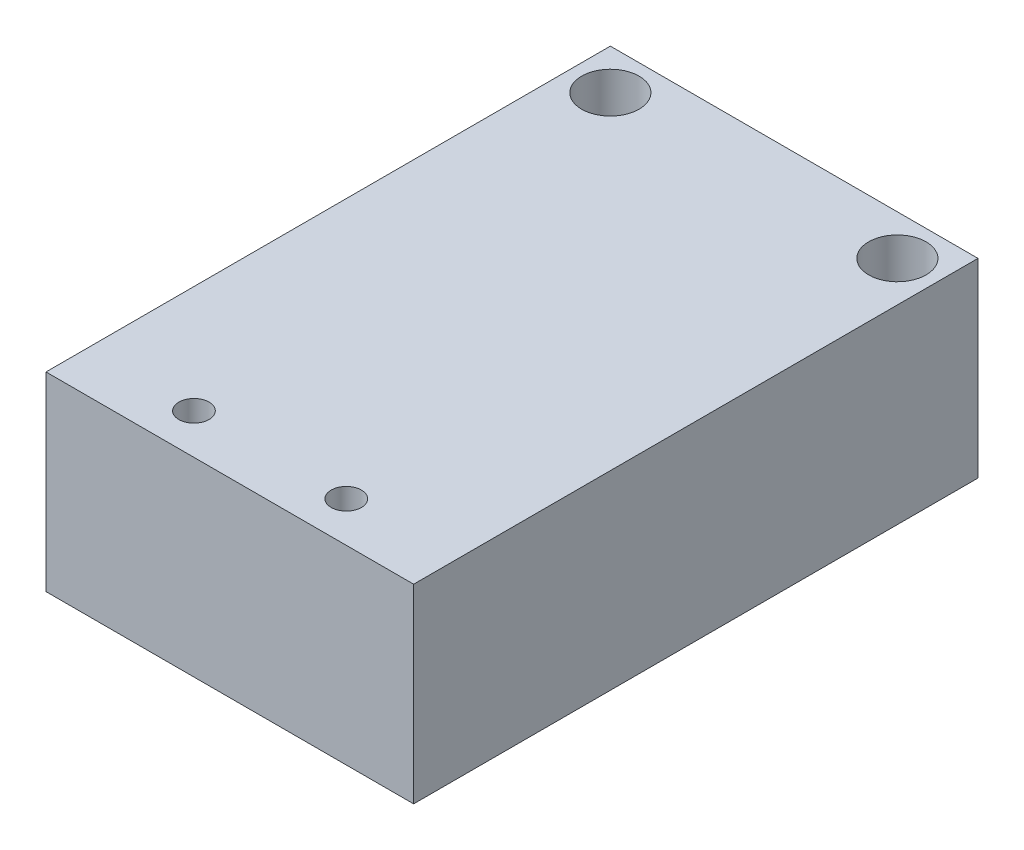
from build123d import *

# Parameters (mm, degrees)
SKETCH1_W             = 14.478
SKETCH1_H             = 22.225
BOSS_EXTRUDE1_DEPTH   = 7.493
F_0_80_TAPPED_HOLE1_D = 1.19126
F_2_CLEARANCE_HOLE1_D = 2.2606


with BuildPart() as part:
    # Sketch1 → Boss-Extrude1 (new body)
    with BuildSketch(Plane(origin=(0, 0, 0), x_dir=(1, 0, 0), z_dir=(0, 1, 0))):
        Rectangle(SKETCH1_W, SKETCH1_H)
    extrude(amount=BOSS_EXTRUDE1_DEPTH)

    # #0-80 Tapped Hole1 (through all)
    with Locations(Plane(origin=(0, 7.493, 0), x_dir=(-1, 0, 0), z_dir=(0, 1, 0))):
        with Locations((3, 9.525), (-3, 9.525)):
            Hole(F_0_80_TAPPED_HOLE1_D / 2)

    # #2 Clearance Hole1 (through all)
    with Locations(Plane(origin=(0, 7.493, 0), x_dir=(-1, 0, 0), z_dir=(0, 1, 0))):
        with Locations((5.6515, -9.525), (-5.6515, -9.525)):
            Hole(F_2_CLEARANCE_HOLE1_D / 2)


solid = part.part
